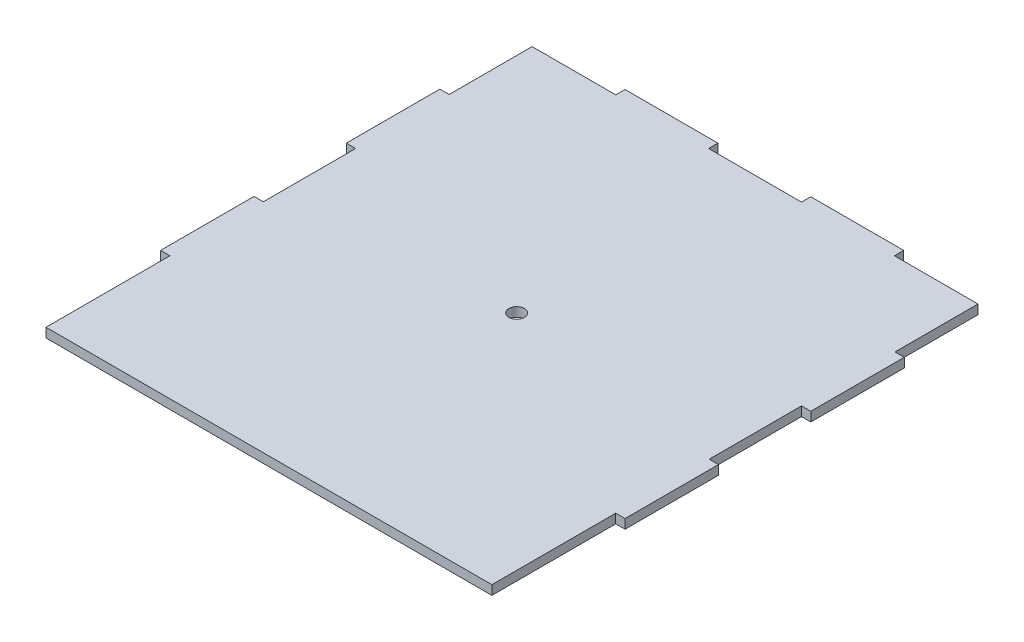
from build123d import *

# Parameters (mm, degrees)
SKETCH1_R           = 2.5
BOSS_EXTRUDE1_DEPTH = 3


with BuildPart() as part:
    # Sketch1 → Boss-Extrude1 (new body)
    with BuildSketch(Plane(origin=(0, 0, 0), x_dir=(1, 0, 0), z_dir=(0, 1, 0))):
        Polygon((150, 130.2), (147, 130.2), (147, 157), (120, 157), (120, 160), (90, 160), (90, 157), (60, 157), (60, 160), (30, 160), (30, 157), (3, 157), (3, 130.2), (0, 130.2), (0, 100), (3, 100), (3, 70.2), (0, 70.2), (0, 40), (3, 40), (3, 0), (147, 0), (147, 40), (150, 40), (150, 70.2), (147, 70.2), (147, 100), (150, 100), align=None)
        with Locations((75, 80)):
            Circle(SKETCH1_R, mode=Mode.SUBTRACT)
    extrude(amount=BOSS_EXTRUDE1_DEPTH)


solid = part.part
